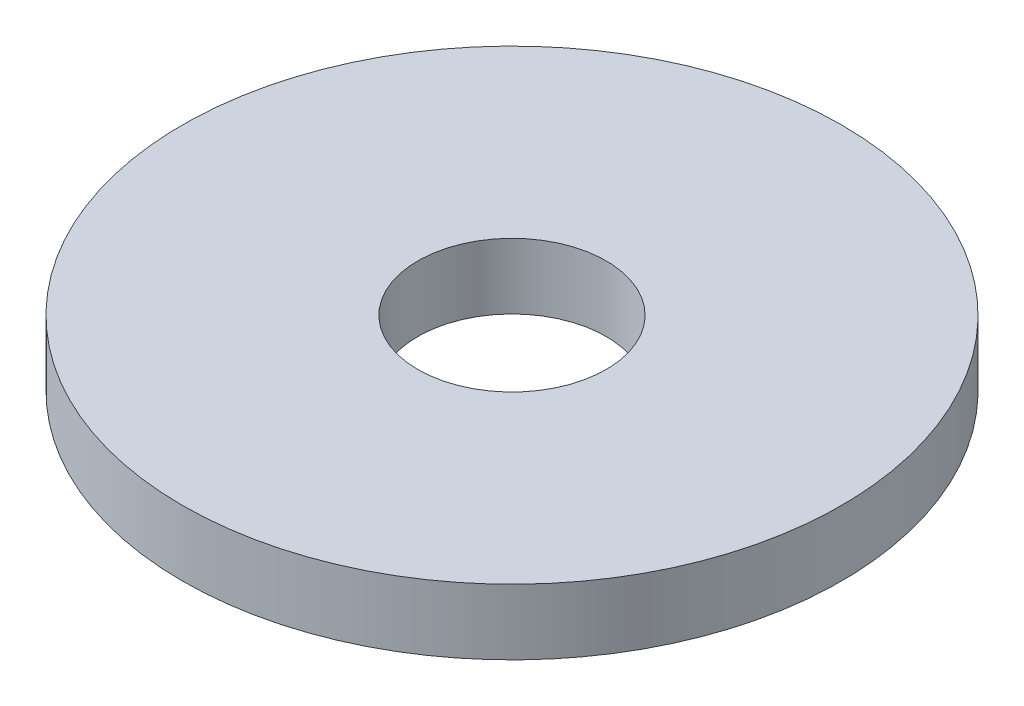
from build123d import *

# Parameters (mm, degrees)
SKETCH1_R           = 11.1125
SKETCH1_R_2         = 3.175
BOSS_EXTRUDE1_DEPTH = 2.2098


with BuildPart() as part:
    # Sketch1 → Boss-Extrude1 (new body)
    with BuildSketch(Plane(origin=(0, 0, 0), x_dir=(1, 0, 0), z_dir=(0, 1, 0))):
        Circle(SKETCH1_R)
        Circle(SKETCH1_R_2, mode=Mode.SUBTRACT)
    extrude(amount=BOSS_EXTRUDE1_DEPTH)


solid = part.part
